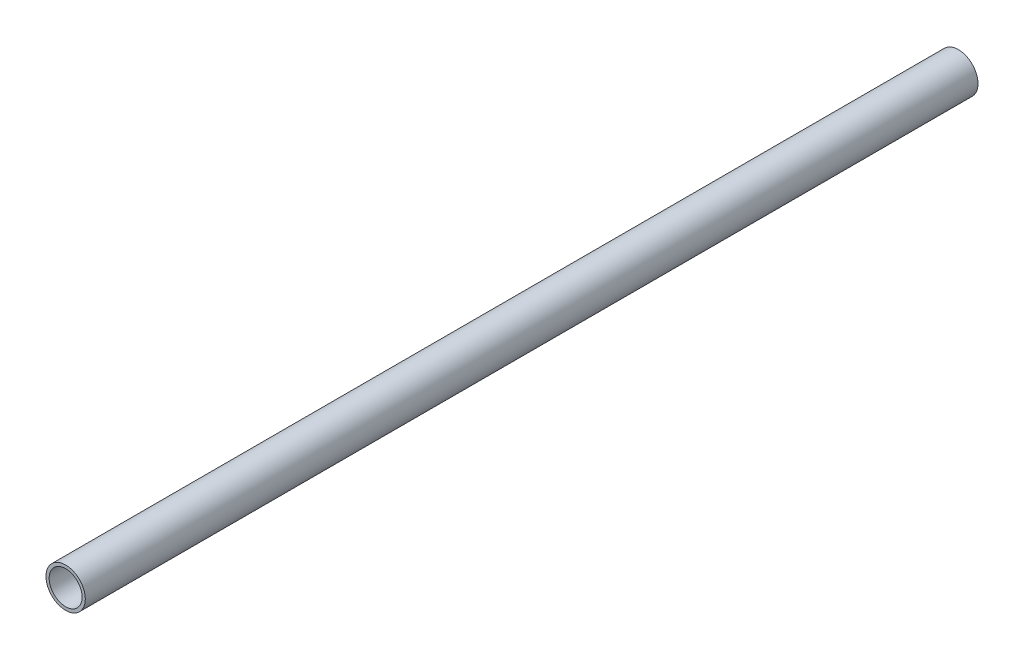
from build123d import *

# Parameters (mm, degrees)
SZKIC1_R                         = 8.35
SZKIC1_R_2                       = 7
DODANIE_WYCI_GNI_CIE1_DEPTH      = 341
DODANIE_WYCI_GNI_CIE1_DEPTH_BACK = 38


with BuildPart() as part:
    # Szkic1 → Dodanie-wyciągnięcie1 (new body, two sides)
    with BuildSketch(Plane.XY) as dodanie_wyci_gni_cie1_sk:
        Circle(SZKIC1_R)
        Circle(SZKIC1_R_2, mode=Mode.SUBTRACT)
    extrude(amount=DODANIE_WYCI_GNI_CIE1_DEPTH)
    extrude(dodanie_wyci_gni_cie1_sk.sketch, amount=-DODANIE_WYCI_GNI_CIE1_DEPTH_BACK)


solid = part.part
